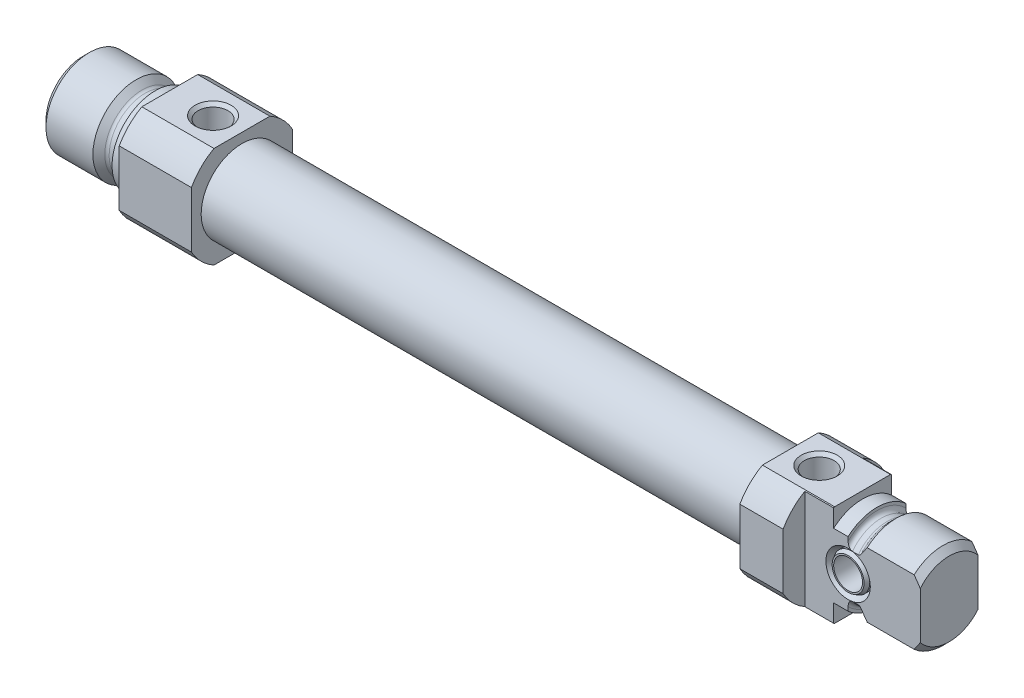
from build123d import *

# Parameters (mm, degrees)
BOSS_EXTRUDE1_DEPTH     = 10
SKETCH3_W               = 76
SKETCH3_H               = 5.65
SKETCH4_W               = 14
SKETCH4_H               = 14
BOSS_EXTRUDE2_DEPTH     = 10
SKETCH5_W               = 10
SKETCH5_H               = 10
CUT_EXTRUDE1_DEPTH      = 8
CUT_EXTRUDE1_DEPTH_BACK = 8
HOLE1_D                 = 4.134
HOLE1_DEPTH             = 7
HOLE1_CSINK_D           = 5
HOLE1_CSINK_ANGLE       = 90
HOLE2_D                 = 4.134
HOLE2_DEPTH             = 8
HOLE2_CSINK_D           = 5
HOLE2_CSINK_ANGLE       = 90
HOLE2_TIP               = 1.193383006


with BuildPart() as part:
    # Sketch1 → Revolve1 (revolve)
    with BuildSketch(Plane.XY):
        with BuildLine():
            Line((0, 0), (0, 5.15))
            Line((0, 5.15), (0.85, 6))
            Line((0.85, 6), (7.35, 6))
            Line((7.35, 6), (8.174264069, 5.175735931))
            ThreePointArc((8.174264069, 5.175735931), (8.368918078, 5.04567228), (8.598528137, 5))
            Line((8.598528137, 5), (9.4, 5))
            ThreePointArc((9.4, 5), (9.824264069, 5.175735931), (10, 5.6))
            Line((10, 5.6), (10, 6))
            Line((10, 6), (12, 6))
            Line((12, 6), (12, 0))
            Line((12, 0), (0, 0))
        make_face()
    revolve(axis=Axis((12, 0, 0), (-1, 0, 0)))

    # Sketch2 → Boss-Extrude1 (add)
    with BuildSketch(Plane(origin=(12, 0, 0), x_dir=(0, 0, -1), z_dir=(1, 0, 0))):
        with BuildLine():
            Line((-3.872983346, -7), (3.872983346, -7))
            ThreePointArc((3.872983346, -7), (5.656854249, -5.656854249), (7, -3.872983346))
            Line((7, -3.872983346), (7, 3.872983346))
            ThreePointArc((7, 3.872983346), (5.656854249, 5.656854249), (3.872983346, 7))
            Line((3.872983346, 7), (-3.872983346, 7))
            ThreePointArc((-3.872983346, 7), (-5.656854249, 5.656854249), (-7, 3.872983346))
            Line((-7, 3.872983346), (-7, -3.872983346))
            ThreePointArc((-7, -3.872983346), (-5.656854249, -5.656854249), (-3.872983346, -7))
        make_face()
    extrude(amount=BOSS_EXTRUDE1_DEPTH)

    # Sketch3 → Revolve2 (revolve)
    with BuildSketch(Plane.XY):
        with Locations((60, 2.825)):
            Rectangle(SKETCH3_W, SKETCH3_H)
    revolve(axis=Axis((98, 0, 0), (-1, 0, 0)))

    # Sketch4 → Boss-Extrude2 (add)
    with BuildSketch(Plane(origin=(98, 0, 0), x_dir=(0, 0, -1), z_dir=(1, 0, 0))):
        Rectangle(SKETCH4_W, SKETCH4_H)
    extrude(amount=BOSS_EXTRUDE2_DEPTH)

    # Sketch5 → Cut-Revolve1 (revolve, cut)
    with BuildSketch(Plane.XY):
        with Locations((103, 13)):
            Rectangle(SKETCH5_W, SKETCH5_H)
    revolve(axis=Axis((108, 0, 0), (-1, 0, 0)), mode=Mode.SUBTRACT)

    # Sketch6 → Revolve3 (revolve)
    with BuildSketch(Plane.XY):
        with BuildLine():
            Line((108, 0), (108, 6))
            Line((108, 6), (110, 6))
            Line((110, 6), (110, 5.6))
            ThreePointArc((110, 5.6), (110.175735931, 5.175735931), (110.6, 5))
            Line((110.6, 5), (111.401471863, 5))
            ThreePointArc((111.401471863, 5), (111.631081922, 5.04567228), (111.825735931, 5.175735931))
            Line((111.825735931, 5.175735931), (112.65, 6))
            Line((112.65, 6), (119.15, 6))
            Line((119.15, 6), (120, 5.15))
            Line((120, 5.15), (120, 0))
            Line((120, 0), (108, 0))
        make_face()
    revolve(axis=Axis((120, 0, 0), (-1, 0, 0)))

    # Sketch7 → Cut-Extrude1 (cut, two sides: drawn at the far end of the back side and taken through both)
    with BuildSketch(Plane(origin=(0, 0, 0), x_dir=(1, 0, 0), z_dir=(0, 1, 0)).offset(-CUT_EXTRUDE1_DEPTH_BACK)):
        Polygon((104, 12), (104, 4), (120, 4), (120, -4), (104, -4), (104, -12), (128, -12), (128, 12), align=None)
    extrude(amount=CUT_EXTRUDE1_DEPTH + CUT_EXTRUDE1_DEPTH_BACK, mode=Mode.SUBTRACT)

    # Sketch8 → Cut-Revolve2 (revolve, cut)
    with BuildSketch(Plane(origin=(110, 0, 0), x_dir=(0, 0, -1), z_dir=(1, 0, 0))):
        Polygon((-4.2, 0), (-4.2, 3.192820323), (-3, 2.5), (-3.5, 2.5), (-4, 2.211324865), (-4, 2), (4, 2), (4, 2.211324865), (3.5, 2.5), (3, 2.5), (4.2, 3.192820323), (4.2, 0), align=None)
    revolve(axis=Axis((110, 0, -4), (0, 0, 1)), mode=Mode.SUBTRACT)

    # Hole1
    with Locations(Plane(origin=(0, 7, 0), x_dir=(1, 0, 0), z_dir=(0, 1, 0))):
        with Locations((18, 0)):
            CounterSinkHole(HOLE1_D / 2, HOLE1_CSINK_D / 2, depth=HOLE1_DEPTH, counter_sink_angle=HOLE1_CSINK_ANGLE)

    # Hole2
    with Locations(Plane(origin=(0, 7, 0), x_dir=(1, 0, 0), z_dir=(0, 1, 0))):
        with Locations((102, 0)):
            CounterSinkHole(HOLE2_D / 2, HOLE2_CSINK_D / 2, depth=HOLE2_DEPTH, counter_sink_angle=HOLE2_CSINK_ANGLE)
            with Locations((0, 0, -(HOLE2_DEPTH + HOLE2_TIP / 2))):  # 120° drill point
                Cone(0, HOLE2_D / 2, HOLE2_TIP, mode=Mode.SUBTRACT)

    # Sketch13 → Cut-Revolve3 (revolve, cut)
    with BuildSketch(Plane.XY):
        Polygon((-4, 0), (-4, 2), (31.5, 2), (31.5, 5), (84, 5), (84, 0), align=None)
    revolve(axis=Axis((84, 0, 0), (-1, 0, 0)), mode=Mode.SUBTRACT)


solid = part.part
